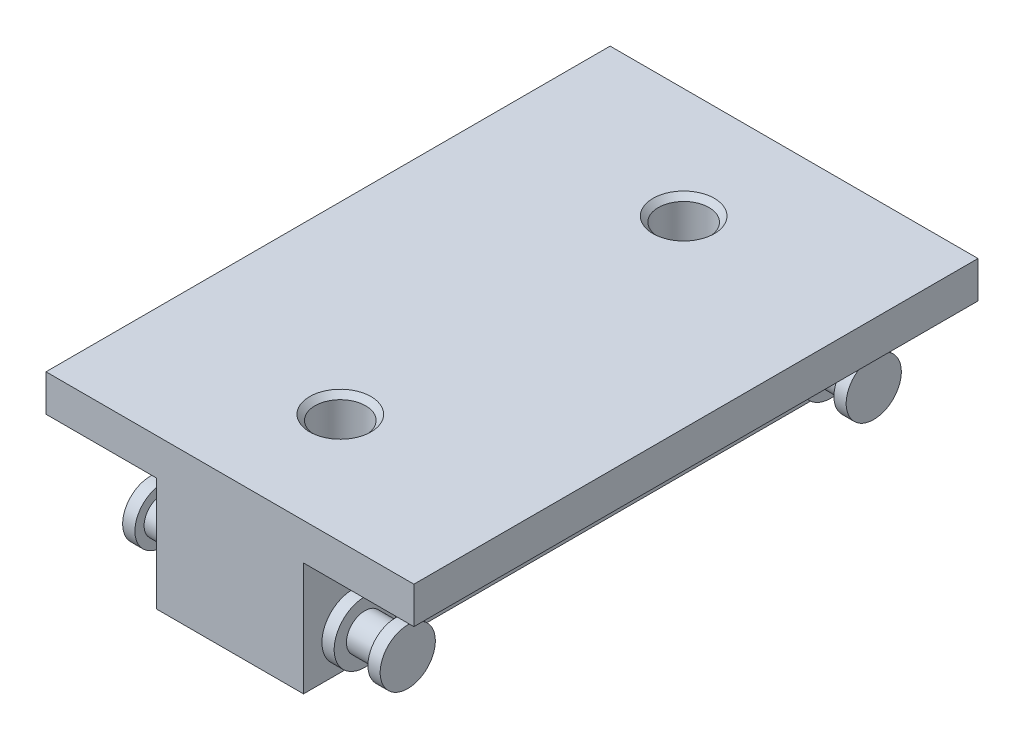
from build123d import *

# Parameters (mm, degrees)
SKETCH_1_W                    = 30
SKETCH_1_H                    = 46
EXTRUDE_1_DEPTH               = 12.25
SKETCH_2_W                    = 9
SKETCH_2_H                    = 9.25
CUT_EXTRUDE_1_DEPTH           = 47
SKETCH_3_W                    = 9
SKETCH_3_H                    = 9.25
CUT_EXTRUDE_2_DEPTH           = 47
HOLE_WIZARD_M3_5_1_AT_2_COUNT = 2
HOLE_WIZARD_M3_5_1_AT_2_PITCH = 28


with BuildPart() as part:
    # 草图1 → 凸台-拉伸1 (new body)
    with BuildSketch(Plane.XZ.offset(6)):
        Rectangle(SKETCH_1_W, SKETCH_1_H)
    extrude(amount=-EXTRUDE_1_DEPTH)

    # 草图2 → 切除-拉伸1 (cut, through all)
    with BuildSketch(Plane(origin=(0, 0, -23), x_dir=(-1, 0, 0), z_dir=(0, 0, -1))):
        with Locations((10.5, -1.375)):
            Rectangle(SKETCH_2_W, SKETCH_2_H)
    extrude(amount=-CUT_EXTRUDE_1_DEPTH, mode=Mode.SUBTRACT)

    # 草图3 → 切除-拉伸2 (cut, through all)
    with BuildSketch(Plane(origin=(0, 0, -23), x_dir=(-1, 0, 0), z_dir=(0, 0, -1))):
        with Locations((-10.5, -1.375)):
            Rectangle(SKETCH_3_W, SKETCH_3_H)
    extrude(amount=-CUT_EXTRUDE_2_DEPTH, mode=Mode.SUBTRACT)

    # 草图4 → 旋转1 (revolve)
    with BuildSketch(Plane.XY.offset(19)):
        Polygon((6, -0.625), (6, -3.125), (10.5, -3.125), (10.5, -0.875), (9.5, -0.875), (9.5, -1.625), (7, -1.625), (7, -0.625), align=None)
    revolve(axis=Axis((6, -3.125, 19), (1, 0, 0)))

    # 草图5 → 旋转2 (revolve)
    with BuildSketch(Plane.XY.offset(19)):
        Polygon((-10.5, -0.875), (-10.5, -3.125), (-6, -3.125), (-6, -0.625), (-7, -0.625), (-7, -1.625), (-9.5, -1.625), (-9.5, -0.875), align=None)
    revolve(axis=Axis((-10.5, -3.125, 19), (1, 0, 0)))

    # 草图6 → 旋转3 (revolve)
    with BuildSketch(Plane.XY.offset(-19)):
        Polygon((6, -0.625), (6, -3.125), (10.5, -3.125), (10.5, -0.875), (9.5, -0.875), (9.5, -1.625), (7, -1.625), (7, -0.625), align=None)
    revolve(axis=Axis((6, -3.125, -19), (1, 0, 0)))

    # 草图7 → 旋转4 (revolve)
    with BuildSketch(Plane.XY.offset(-19)):
        Polygon((-10.5, -0.875), (-10.5, -3.125), (-6, -3.125), (-6, -0.625), (-7, -0.625), (-7, -1.625), (-9.5, -1.625), (-9.5, -0.875), align=None)
    revolve(axis=Axis((-10.5, -3.125, -19), (1, 0, 0)))

    # 草图8 → M3.5 平头机械螺钉的锥形沉头孔1 (revolve, cut)
    with BuildSketch(Plane(origin=(0, -6, -14), x_dir=(0, 0, -1), z_dir=(1, 0, 0))):
        Polygon((0, 0), (0, 12.25), (2.5, 12.25), (2.067, 11.817), (2.067, 0.433), (2.5, 0), align=None)
    hole_wizard_m3_5_1 = revolve(axis=Axis((0, -12.35, -14), (0, 1, 0)), mode=Mode.SUBTRACT)

    # M3.5 平头机械螺钉的锥形沉头孔1 at 2: M3.5 平头机械螺钉的锥形沉头孔1 ×2
    with Locations(*[(0, 0, i * HOLE_WIZARD_M3_5_1_AT_2_PITCH) for i in range(1, HOLE_WIZARD_M3_5_1_AT_2_COUNT)]):
        add(hole_wizard_m3_5_1, mode=Mode.SUBTRACT)


solid = part.part
